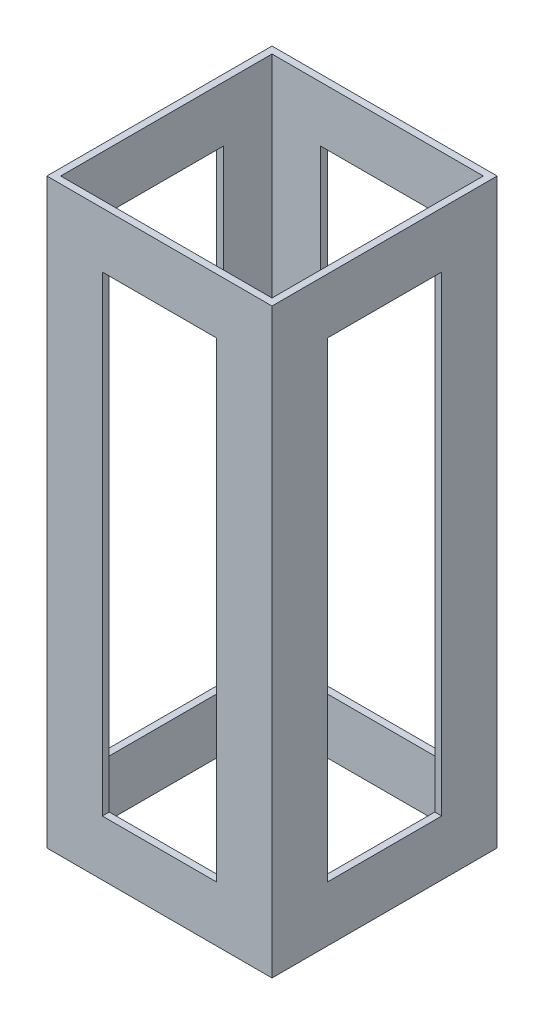
from build123d import *

# Parameters (mm, degrees)
SKETCH1_W               = 103.1875
SKETCH1_H               = 103.1875
SKETCH1_W_2             = 96.8375
SKETCH1_H_2             = 96.8375
BOSS_EXTRUDE1_DEPTH     = 266.7
SKETCH2_W               = 52.3875
SKETCH2_H               = 215.9
CUT_EXTRUDE2_DEPTH      = 52.59375
CUT_EXTRUDE2_DEPTH_BACK = 52.59375
SKETCH3_W               = 52.3875
SKETCH3_H               = 215.9
CUT_EXTRUDE3_DEPTH      = 52.59375
CUT_EXTRUDE3_DEPTH_BACK = 52.59375


with BuildPart() as part:
    # Sketch1 → Boss-Extrude1 (new body)
    with BuildSketch(Plane(origin=(0, 0, 0), x_dir=(1, 0, 0), z_dir=(0, 1, 0))):
        Rectangle(SKETCH1_W, SKETCH1_H)
        Rectangle(SKETCH1_W_2, SKETCH1_H_2, mode=Mode.SUBTRACT)
    extrude(amount=BOSS_EXTRUDE1_DEPTH)

    # Sketch2 → Cut-Extrude2 (cut, two sides)
    with BuildSketch(Plane.XY) as cut_extrude2_sk:
        with Locations((0, 133.35)):
            Rectangle(SKETCH2_W, SKETCH2_H)
    extrude(amount=CUT_EXTRUDE2_DEPTH, mode=Mode.SUBTRACT)
    extrude(cut_extrude2_sk.sketch, amount=-CUT_EXTRUDE2_DEPTH_BACK, mode=Mode.SUBTRACT)

    # Sketch3 → Cut-Extrude3 (cut, two sides)
    with BuildSketch(Plane(origin=(0, 0, 0), x_dir=(0, 0, -1), z_dir=(1, 0, 0))) as cut_extrude3_sk:
        with Locations((0, 133.35)):
            Rectangle(SKETCH3_W, SKETCH3_H)
    extrude(amount=CUT_EXTRUDE3_DEPTH, mode=Mode.SUBTRACT)
    extrude(cut_extrude3_sk.sketch, amount=-CUT_EXTRUDE3_DEPTH_BACK, mode=Mode.SUBTRACT)


solid = part.part
